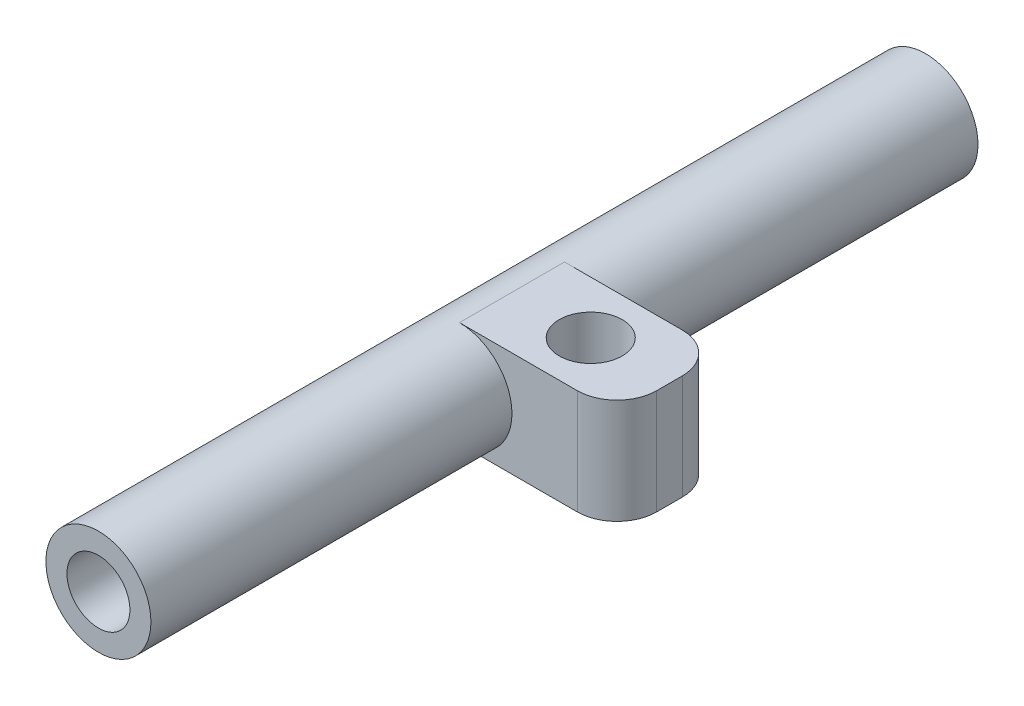
from build123d import *

# Parameters (mm, degrees)
SKETCH1_R           = 9.525
BOSS_EXTRUDE1_DEPTH = 125
BOSS_EXTRUDE2_DEPTH = 15.875
SKETCH2_R           = 9.525
CUT_EXTRUDE1_DEPTH  = 25.4
FILLET1_R           = 12


with BuildPart() as part:
    # Sketch1 → Boss-Extrude1 (new, symmetric)
    with BuildSketch(Plane.XY):
        with BuildLine():
            ThreePointArc((9.7e-16, 15.875), (-15.875, 1.94e-15), (-2.92e-15, -15.875))
            ThreePointArc((-2.92e-15, -15.875), (11.225320151336438, -11.225320151336444), (15.875, -3.89e-15))
            ThreePointArc((15.875, 0), (11.225320151336442, 11.22532015133644), (9.7e-16, 15.875))
        make_face()
        Circle(SKETCH1_R, mode=Mode.SUBTRACT)
    extrude(amount=BOSS_EXTRUDE1_DEPTH, both=True)

    # Sketch1_3 → Boss-Extrude2 (add, symmetric)
    with BuildSketch(Plane.XY):
        with BuildLine():
            ThreePointArc((0, 15.875), (15.875, 9.7e-16), (1.94e-15, -15.875))
            Line((0, -15.875), (47.625, -15.874999999999996))
            Line((47.625, -15.874999999999996), (47.62499999999999, 15.874999999999996))
            Line((47.62499999999999, 15.874999999999996), (0, 15.875))
        make_face()
    extrude(amount=BOSS_EXTRUDE2_DEPTH, both=True)

    # Sketch2 → Cut-Extrude1 (cut)
    with BuildSketch(Plane(origin=(1.16e-15, 15.875, 0), x_dir=(1, -7e-17, 0), z_dir=(7e-17, 1, 0))):
        with Locations((23.8125, 0)):
            Circle(SKETCH2_R)
    extrude(amount=-CUT_EXTRUDE1_DEPTH, mode=Mode.SUBTRACT)

    # Fillet1
    fillet1_edges = [part.edges().sort_by_distance(p)[0] for p in [
        (47.625, 0, -15.875),
        (47.625, 0, 15.875),
    ]]
    fillet(fillet1_edges, radius=FILLET1_R)


solid = part.part
